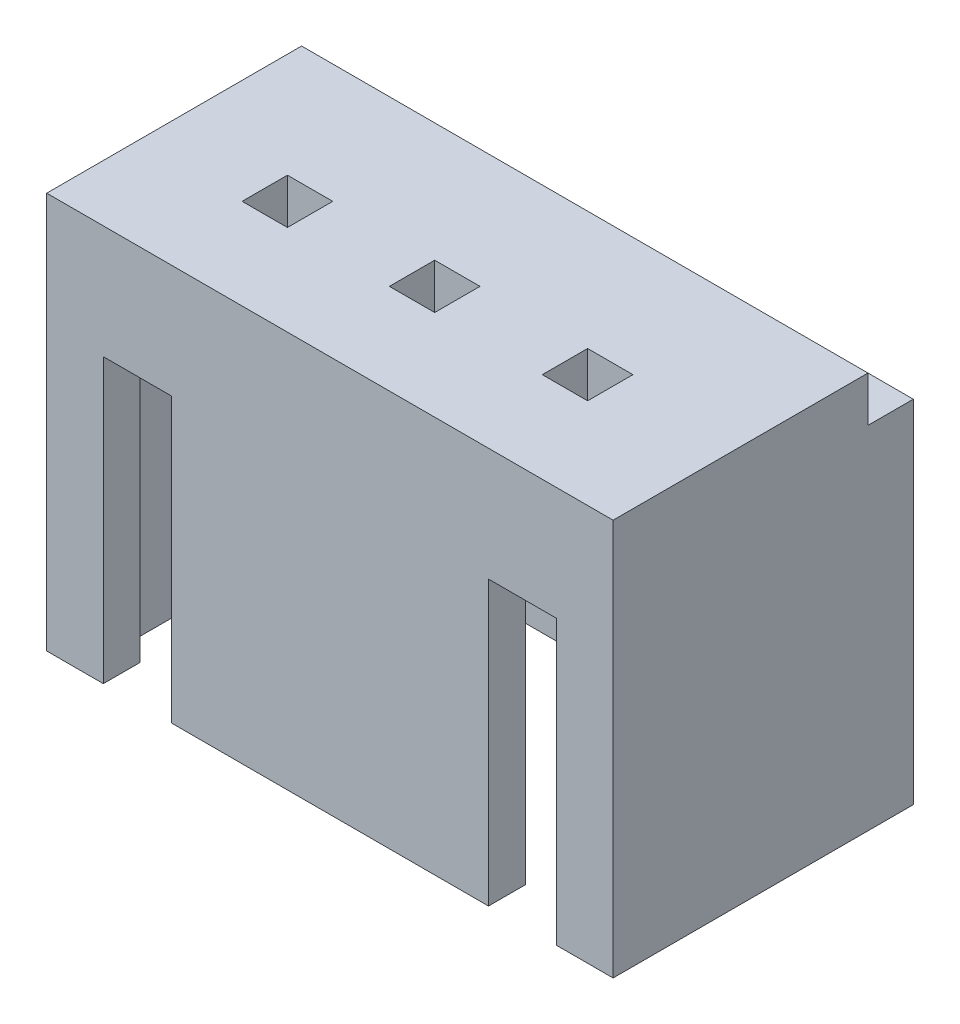
from build123d import *

# Parameters (mm, degrees)
SKETCH1_W           = 10
SKETCH1_H           = 5.3
BOSS_EXTRUDE1_DEPTH = 7
SKETCH3_W           = 8.8
SKETCH3_H           = 4
CUT_EXTRUDE1_DEPTH  = 5
SKETCH4_W           = 1.2
SKETCH4_H           = 5
CUT_EXTRUDE2_DEPTH  = 4
SKETCH5_W           = 10
SKETCH5_H           = 0.8
CUT_EXTRUDE3_DEPTH  = 0.8
SKETCH6_W           = 0.8
SKETCH6_H           = 0.8
CUT_EXTRUDE4_DEPTH  = 10
SKETCH7_W           = 8.8
SKETCH7_H           = 1
CUT_EXTRUDE5_DEPTH  = 0.3


with BuildPart() as part:
    # Sketch1 → Boss-Extrude1 (new body)
    with BuildSketch(Plane(origin=(0, 0, 0), x_dir=(1, 0, 0), z_dir=(0, 1, 0))):
        Rectangle(SKETCH1_W, SKETCH1_H)
    extrude(amount=BOSS_EXTRUDE1_DEPTH)

    # Sketch3 → Cut-Extrude1 (cut)
    with BuildSketch(Plane.XZ):
        Rectangle(SKETCH3_W, SKETCH3_H)
    extrude(amount=-CUT_EXTRUDE1_DEPTH, mode=Mode.SUBTRACT)

    # Sketch4 → Cut-Extrude2 (cut)
    with BuildSketch(Plane.XY.offset(2.65)):
        with Locations((-3.4, 2.5)):
            Rectangle(SKETCH4_W, SKETCH4_H)
        with Locations((3.4, 2.5)):
            Rectangle(SKETCH4_W, SKETCH4_H)
    extrude(amount=-CUT_EXTRUDE2_DEPTH, mode=Mode.SUBTRACT)

    # Sketch5 → Cut-Extrude3 (cut)
    with BuildSketch(Plane(origin=(0, 7, 0), x_dir=(1, 0, 0), z_dir=(0, 1, 0))):
        with Locations((0, 2.25)):
            Rectangle(SKETCH5_W, SKETCH5_H)
    extrude(amount=-CUT_EXTRUDE3_DEPTH, mode=Mode.SUBTRACT)

    # Sketch6 → Cut-Extrude4 (cut)
    with BuildSketch(Plane(origin=(0, 7, 0), x_dir=(1, 0, 0), z_dir=(0, 1, 0))):
        with Locations((2.55, -0.65)):
            Rectangle(SKETCH6_W, SKETCH6_H)
        with Locations((-0.15, -0.65)):
            Rectangle(SKETCH6_W, SKETCH6_H)
        with Locations((-2.75, -0.65)):
            Rectangle(SKETCH6_W, SKETCH6_H)
    extrude(amount=-CUT_EXTRUDE4_DEPTH, mode=Mode.SUBTRACT)

    # Sketch7 → Cut-Extrude5 (cut)
    with BuildSketch(Plane.XZ.offset(-5)):
        with Locations((0, -1.5)):
            Rectangle(SKETCH7_W, SKETCH7_H)
    extrude(amount=-CUT_EXTRUDE5_DEPTH, mode=Mode.SUBTRACT)


solid = part.part
